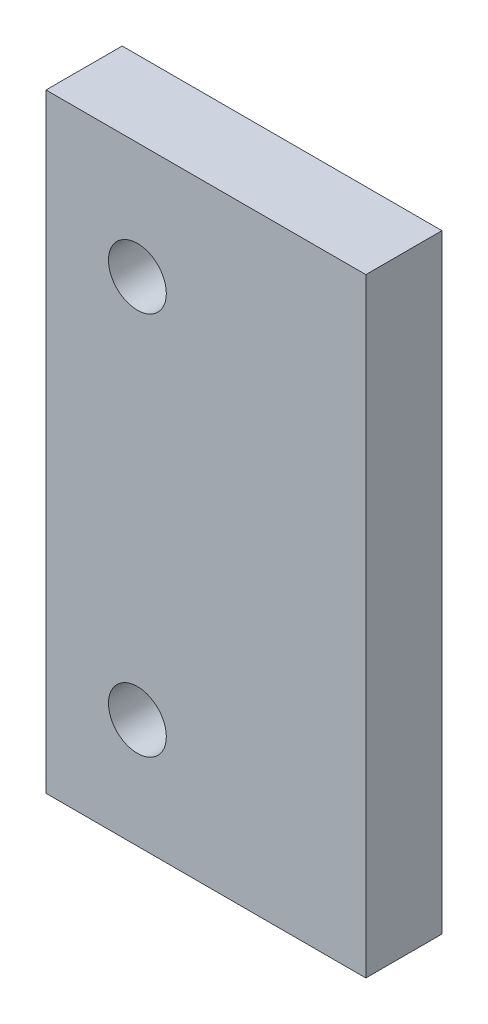
from build123d import *

# Parameters (mm, degrees)
SKETCH2_W           = 10.5
SKETCH2_H           = 20
BOSS_EXTRUDE1_DEPTH = 2.5
SKETCH3_R           = 0.95
CUT_EXTRUDE1_DEPTH  = 3.5


with BuildPart() as part:
    # Sketch2 → Boss-Extrude1 (new body)
    with BuildSketch(Plane.XY):
        with Locations((5.25, 10)):
            Rectangle(SKETCH2_W, SKETCH2_H)
    extrude(amount=BOSS_EXTRUDE1_DEPTH)

    # Sketch3 → Cut-Extrude1 (cut, through all)
    with BuildSketch(Plane.XY.offset(2.5)):
        with Locations((3, 16.188280357)):
            Circle(SKETCH3_R)
        with Locations((3, 3.588280357)):
            Circle(SKETCH3_R)
    extrude(amount=-CUT_EXTRUDE1_DEPTH, mode=Mode.SUBTRACT)


solid = part.part
